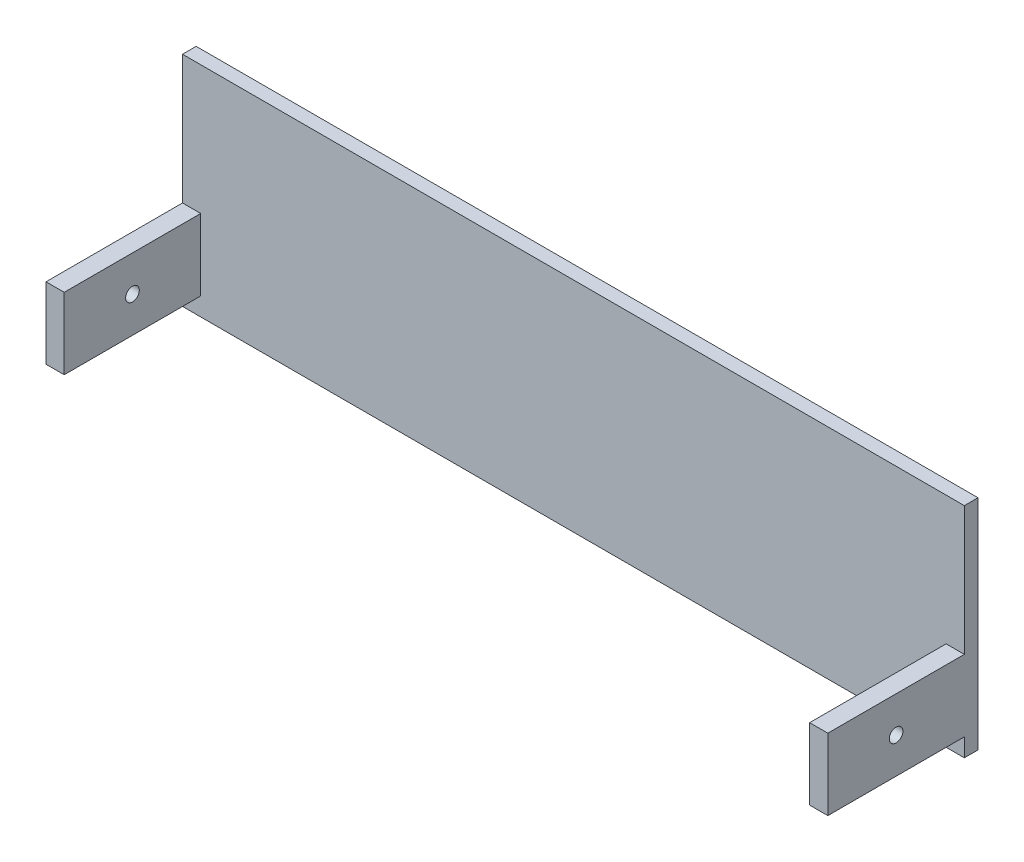
from build123d import *

# Parameters (mm, degrees)
CROQUIS1_W              = 171.8
CROQUIS1_H              = 48
SALIENTE_EXTRUIR1_DEPTH = 3
CROQUIS2_W              = 4
CROQUIS2_H              = 44
SALIENTE_EXTRUIR2_DEPTH = 30
CORTAR_EXTRUIR1_START   = -171.8
CROQUIS3_W              = 30
CROQUIS3_H              = 28.304126214
CORTAR_EXTRUIR1_DEPTH   = 171.8
CORTAR_EXTRUIR2_START   = -171.8
CROQUIS4_R              = 1.5
CORTAR_EXTRUIR2_DEPTH   = 171.8


with BuildPart() as part:
    # Croquis1 → Saliente-Extruir1 (new body)
    with BuildSketch(Plane.XY):
        with Locations((-85.9, 24)):
            Rectangle(CROQUIS1_W, CROQUIS1_H)
    extrude(amount=SALIENTE_EXTRUIR1_DEPTH)

    # Croquis2 → Saliente-Extruir2 (add)
    with BuildSketch(Plane.XY.offset(3)):
        with Locations((-169.8, 26)):
            Rectangle(CROQUIS2_W, CROQUIS2_H)
        with Locations((-2, 26)):
            Rectangle(CROQUIS2_W, CROQUIS2_H)
    extrude(amount=SALIENTE_EXTRUIR2_DEPTH)

    # Croquis3 → Cortar-Extruir1 (cut)
    with BuildSketch(Plane.ZY.offset(171.8).offset(CORTAR_EXTRUIR1_START)):
        with Locations((18, 33.847936893)):
            Rectangle(CROQUIS3_W, CROQUIS3_H)
    extrude(amount=CORTAR_EXTRUIR1_DEPTH, mode=Mode.SUBTRACT)

    # Croquis4 → Cortar-Extruir2 (cut)
    with BuildSketch(Plane.ZY.offset(171.8).offset(CORTAR_EXTRUIR2_START)):
        with Locations((18, 11.847936893)):
            Circle(CROQUIS4_R)
    extrude(amount=CORTAR_EXTRUIR2_DEPTH, mode=Mode.SUBTRACT)


solid = part.part
